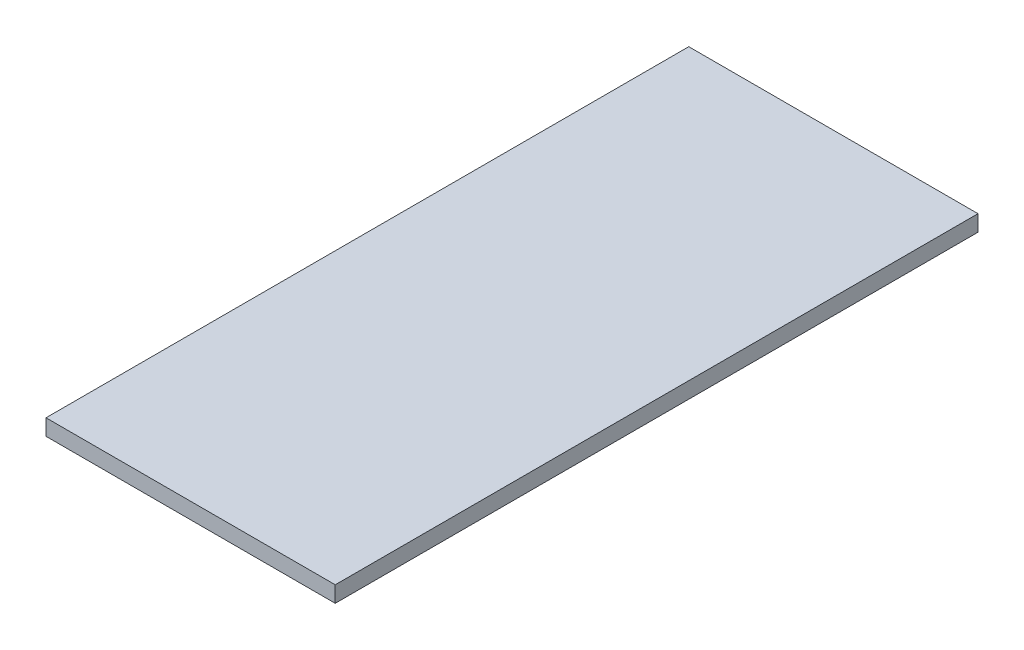
from build123d import *

# Parameters (mm, degrees)
SKETCH1_W           = 27
SKETCH1_H           = 60
BOSS_EXTRUDE1_DEPTH = 1.5


with BuildPart() as part:
    # Sketch1 → Boss-Extrude1 (new body)
    with BuildSketch(Plane(origin=(0, 0, 0), x_dir=(1, 0, 0), z_dir=(0, 1, 0))):
        Rectangle(SKETCH1_W, SKETCH1_H)
    extrude(amount=BOSS_EXTRUDE1_DEPTH)


solid = part.part
